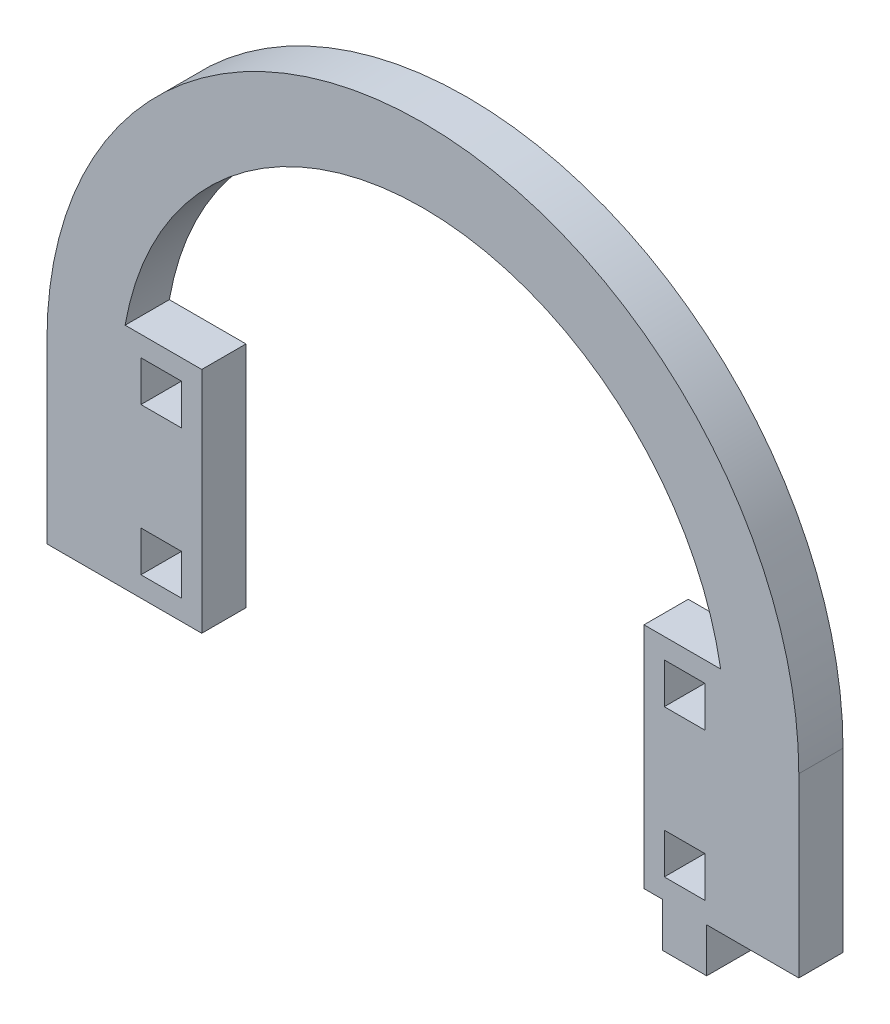
from build123d import *

# Parameters (mm, degrees)
MODEL_W             = 5.5
MODEL_H             = 5.5
BOSS_EXTRUDE1_DEPTH = 6


with BuildPart() as part:
    # Model → Boss-Extrude1 (new body)
    with BuildSketch(Plane.XY):
        with BuildLine():
            Line((3452.90039403, 1295.068502361), (3452.90039403, 1271.068502361))
            Line((3452.90039403, 1271.068502361), (3462.90039403, 1271.068502361))
            Line((3462.90039403, 1271.068502361), (3473.90039403, 1271.068502361))
            Line((3473.90039403, 1271.068502361), (3473.90039403, 1302.068502361))
            Line((3473.90039403, 1302.068502361), (3463.502374277, 1302.068502361))
            ThreePointArc((3463.502374277, 1302.068502361), (3503.90039403, 1336.068502361), (3544.298413784, 1302.068502361))
            Line((3544.298413784, 1302.068502361), (3533.90039403, 1302.068502361))
            Line((3533.90039403, 1302.068502361), (3533.90039403, 1271.068502361))
            Line((3533.90039403, 1271.068502361), (3536.40039403, 1271.068502361))
            Line((3536.40039403, 1271.068502361), (3536.40039403, 1265.068502361))
            Line((3536.40039403, 1265.068502361), (3542.40039403, 1265.068502361))
            Line((3542.40039403, 1265.068502361), (3542.40039403, 1271.068502361))
            Line((3542.40039403, 1271.068502361), (3554.90039403, 1271.068502361))
            Line((3554.90039403, 1271.068502361), (3554.90039403, 1295.068502361))
            ThreePointArc((3554.90039403, 1295.068502361), (3503.90039403, 1346.068502361), (3452.90039403, 1295.068502361))
        make_face()
        with Locations((3539.40039403, 1276.568502361)):
            Rectangle(MODEL_W, MODEL_H, mode=Mode.SUBTRACT)
        with Locations((3539.40039403, 1296.568502361)):
            Rectangle(MODEL_W, MODEL_H, mode=Mode.SUBTRACT)
        with Locations((3468.40039403, 1276.568502361)):
            Rectangle(MODEL_W, MODEL_H, mode=Mode.SUBTRACT)
        with Locations((3468.40039403, 1296.568502361)):
            Rectangle(MODEL_W, MODEL_H, mode=Mode.SUBTRACT)
    extrude(amount=BOSS_EXTRUDE1_DEPTH)


solid = part.part
